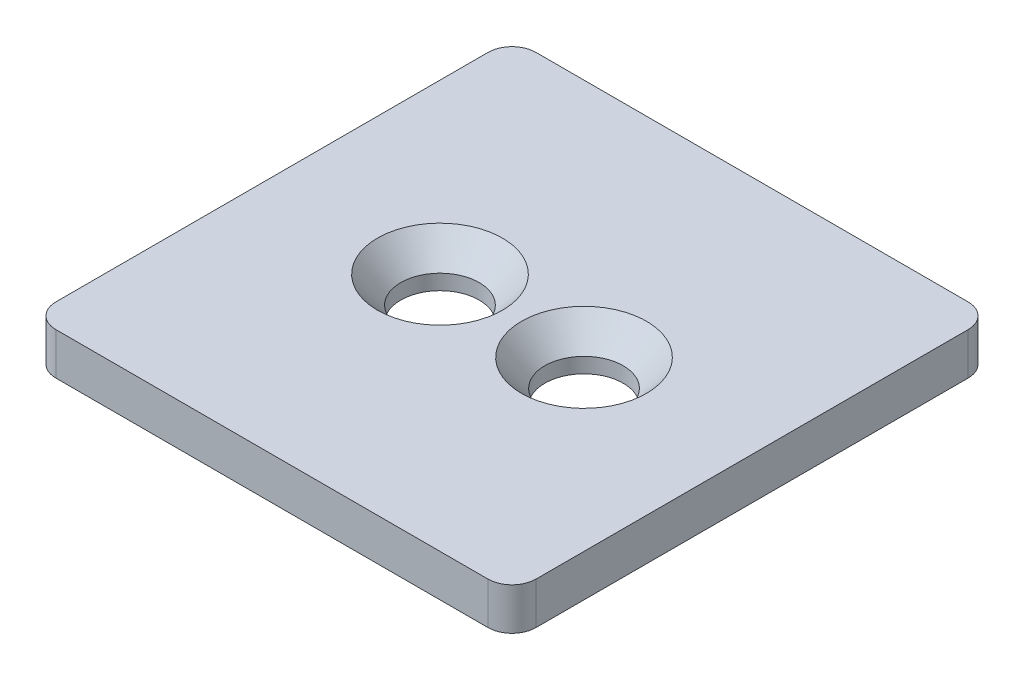
from build123d import *

# Parameters (mm, degrees)
SKETCH1_W                                     = 20
SKETCH1_H                                     = 20
BOSS_EXTRUDE1_DEPTH                           = 1.75
CSK_FOR_4_FLAT_HEAD_MACHINE_SCREW1_AT_2_COUNT = 2
CSK_FOR_4_FLAT_HEAD_MACHINE_SCREW1_AT_2_PITCH = 6
FILLET2_R                                     = 1


with BuildPart() as part:
    # Sketch1 → Boss-Extrude1 (new body)
    with BuildSketch(Plane(origin=(0, 0, 0), x_dir=(1, 0, 0), z_dir=(0, 1, 0))):
        Rectangle(SKETCH1_W, SKETCH1_H)
    extrude(amount=BOSS_EXTRUDE1_DEPTH)

    # Sketch4 → CSK for #4 Flat Head Machine Screw1 (revolve, cut)
    with BuildSketch(Plane(origin=(3, 1.75, 0), x_dir=(0, 0, 1), z_dir=(1, 0, 0))):
        Polygon((0, 0), (0, 1.75), (1.63195, 1.75), (1.63195, 1.117640426), (2.6035, 0), align=None)
    csk_for_4_flat_head_machine_screw1 = revolve(axis=Axis((3, 8.1, 0), (0, -1, 0)), mode=Mode.SUBTRACT)

    # CSK for #4 Flat Head Machine Screw1 at 2: CSK for #4 Flat Head Machine Screw1 ×2
    with Locations(*[(-i * CSK_FOR_4_FLAT_HEAD_MACHINE_SCREW1_AT_2_PITCH, 0, 0) for i in range(1, CSK_FOR_4_FLAT_HEAD_MACHINE_SCREW1_AT_2_COUNT)]):
        add(csk_for_4_flat_head_machine_screw1, mode=Mode.SUBTRACT)

    # Fillet2
    fillet2_edges = [part.edges().sort_by_distance(p)[0] for p in [
        (10, 0.875, 10),
        (-10, 0.875, 10),
        (-10, 0.875, -10),
        (10, 0.875, -10),
    ]]
    fillet(fillet2_edges, radius=FILLET2_R)


solid = part.part
